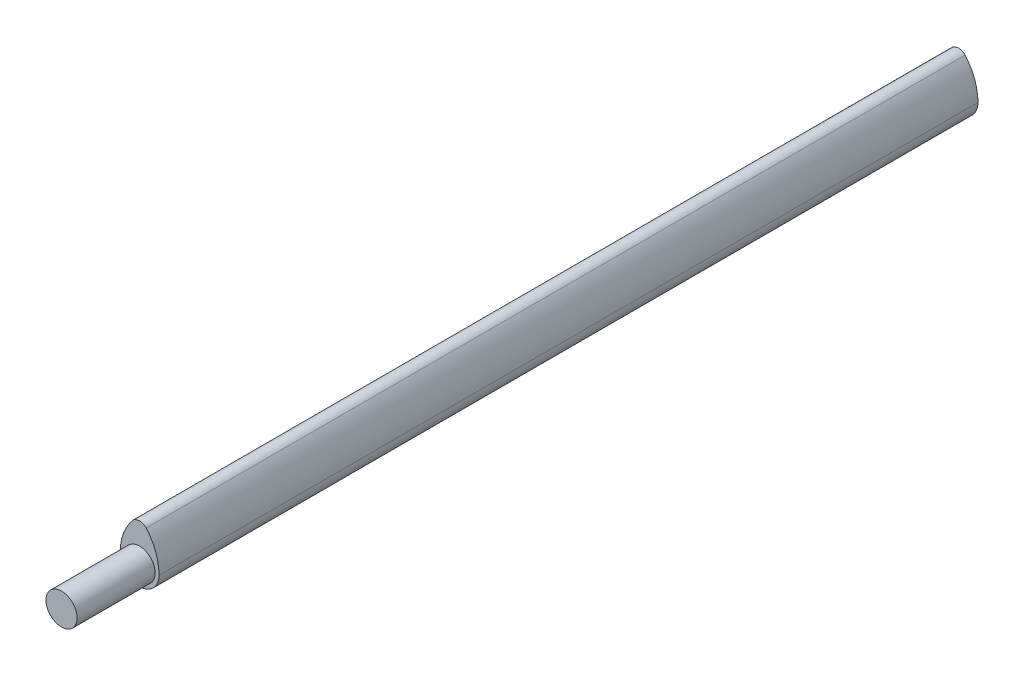
from build123d import *

# Parameters (mm, degrees)
SKETCH1_R           = 5
BOSS_EXTRUDE1_DEPTH = 210
BOSS_EXTRUDE2_DEPTH = 210
SKETCH3_R           = 3.996327594
BOSS_EXTRUDE3_DEPTH = 20


with BuildPart() as part:
    # Sketch1 → Boss-Extrude1 (new body)
    with BuildSketch(Plane.XY):
        Circle(SKETCH1_R)
    extrude(amount=-BOSS_EXTRUDE1_DEPTH)

    # Sketch2 → Boss-Extrude2 (add)
    with BuildSketch(Plane.XY):
        with BuildLine():
            Line((-5, 0), (5, 0))
            ThreePointArc((5, 0), (4.149899422, 4.734754346), (1.70579093, 8.878050545))
            ThreePointArc((1.70579093, 8.878050545), (0, 9.584612283), (-1.70579093, 8.878050545))
            ThreePointArc((-1.70579093, 8.878050545), (-4.149899422, 4.734754346), (-5, 0))
        make_face()
    extrude(amount=-BOSS_EXTRUDE2_DEPTH)

    # Sketch3 → Boss-Extrude3 (add)
    with BuildSketch(Plane.XY):
        Circle(SKETCH3_R)
    extrude(amount=BOSS_EXTRUDE3_DEPTH)


solid = part.part
